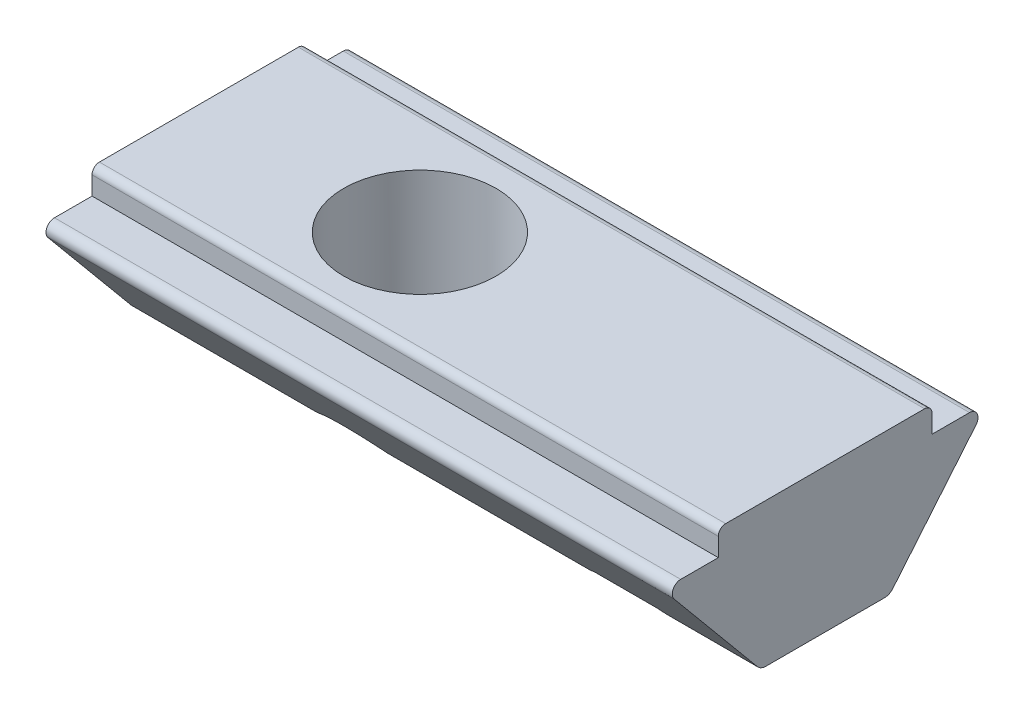
from build123d import *

# Parameters (mm, degrees)
BOSS_EXTRUDE1_DEPTH = 17
FILLET1_R           = 0.3
FILLET2_R           = 0.2
SKETCH2_W           = 2.1
SKETCH2_H           = 0.2
TAPPED_HOLE1_D      = 4.134


with BuildPart() as part:
    # Sketch1 → Boss-Extrude1 (new body)
    with BuildSketch(Plane(origin=(-6, 0, 0), x_dir=(0, 0, -1), z_dir=(1, 0, 0))):
        with BuildLine():
            Line((2.9, 0), (-2.9, 0))
            Line((-2.9, 0), (-2.9, -0.7))
            Line((-2.9, -0.7), (-3.92, -0.7))
            ThreePointArc((-3.92, -0.7), (-4.128228295, -0.832322075), (-4.096863547, -1.077034982))
            Line((-4.096863547, -1.077034982), (-1.75, -3.9))
            Line((-1.75, -3.9), (1.75, -3.9))
            Line((1.75, -3.9), (4.096863547, -1.077034982))
            ThreePointArc((4.096863547, -1.077034982), (4.128228295, -0.832322075), (3.92, -0.7))
            Line((3.92, -0.7), (2.9, -0.7))
            Line((2.9, -0.7), (2.9, 0))
        make_face()
    extrude(amount=BOSS_EXTRUDE1_DEPTH)

    # Fillet1
    fillet1_edges = [part.edges().sort_by_distance(p)[0] for p in [
        (2.5, -3.9, -1.75),
        (2.5, -3.9, 1.75),
    ]]
    fillet(fillet1_edges, radius=FILLET1_R)

    # Fillet2
    fillet2_edges = [part.edges().sort_by_distance(p)[0] for p in [
        (2.5, 0, 2.9),
        (2.5, 0, -2.9),
    ]]
    fillet(fillet2_edges, radius=FILLET2_R)

    # Sketch2 → Cut-Revolve1 (revolve, cut)
    with BuildSketch(Plane(origin=(7.5, 0, 0), x_dir=(0, 0, -1), z_dir=(1, 0, 0))):
        with Locations((1.05, -3.8)):
            Rectangle(SKETCH2_W, SKETCH2_H)
    revolve(axis=Axis((7.5, 1.665548573, 0), (0, -1, 0)), mode=Mode.SUBTRACT)

    # Sketch3 → Revolve1 (revolve)
    with BuildSketch(Plane(origin=(7.5, 0, 0), x_dir=(0, 0, -1), z_dir=(1, 0, 0))):
        with BuildLine():
            Line((1.732050808, -3.7), (0, -3.7))
            Line((0, -3.7), (0, -4.7))
            ThreePointArc((0, -4.7), (1, -4.432050808), (1.732050808, -3.7))
        make_face()
    revolve(axis=Axis((7.5, 0, 0), (0, -1, 0)))

    # Tapped Hole1 (through all)
    with Locations(Plane(origin=(0, 0, 0), x_dir=(1, 0, 0), z_dir=(0, 1, 0))):
        with Locations((0, 0)):
            Hole(TAPPED_HOLE1_D / 2)


solid = part.part
